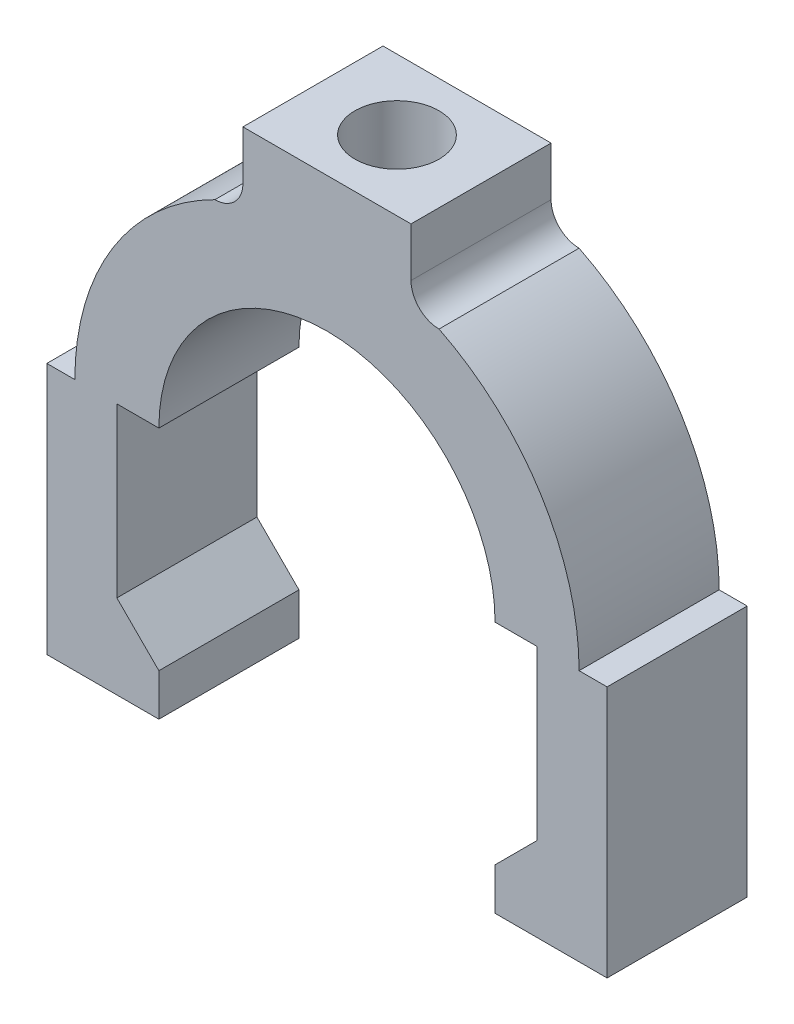
from build123d import *

# Parameters (mm, degrees)
BOSS_EXTRUDE1_DEPTH = 20
SKETCH2_R           = 6
CUT_EXTRUDE1_DEPTH  = 20


with BuildPart() as part:
    # Sketch1 → Boss-Extrude1 (new body)
    with BuildSketch(Plane.XY):
        with BuildLine():
            Line((0, 0), (0, -7))
            ThreePointArc((0, -7), (-1.171572875, -9.828427125), (-4, -11))
            ThreePointArc((-4, -11), (-18.594117082, -24.275365032), (-24, -43.249030993))
            Line((-24, -43.249030993), (-28, -43.249030993))
            Line((-28, -43.249030993), (-28, -79.249030993))
            Line((-28, -79.249030993), (-12, -79.249030993))
            Line((-12, -79.249030993), (-12, -73.249030993))
            Line((-12, -73.249030993), (-18, -67.249030993))
            Line((-18, -67.249030993), (-18, -43.249030993))
            Line((-18, -43.249030993), (-12, -43.249030993))
            ThreePointArc((-12, -43.249030993), (12, -19.249030993), (36, -43.249030993))
            Line((36, -43.249030993), (42, -43.249030993))
            Line((42, -43.249030993), (42, -67.249030993))
            Line((42, -67.249030993), (36, -73.249030993))
            Line((36, -73.249030993), (36, -79.249030993))
            Line((36, -79.249030993), (52, -79.249030993))
            Line((52, -79.249030993), (52, -43.249030993))
            Line((52, -43.249030993), (48, -43.249030993))
            ThreePointArc((48, -43.249030993), (42.594117082, -24.275365032), (28, -11))
            ThreePointArc((28, -11), (25.171572875, -9.828427125), (24, -7))
            Line((24, -7), (24, 0))
            Line((24, 0), (0, 0))
        make_face()
    extrude(amount=BOSS_EXTRUDE1_DEPTH)

    # Sketch2 → Cut-Extrude1 (cut)
    with BuildSketch(Plane(origin=(0, 0, 0), x_dir=(1, 0, 0), z_dir=(0, 1, 0))):
        with Locations((12, -10)):
            Circle(SKETCH2_R)
    extrude(amount=-CUT_EXTRUDE1_DEPTH, mode=Mode.SUBTRACT)


solid = part.part
